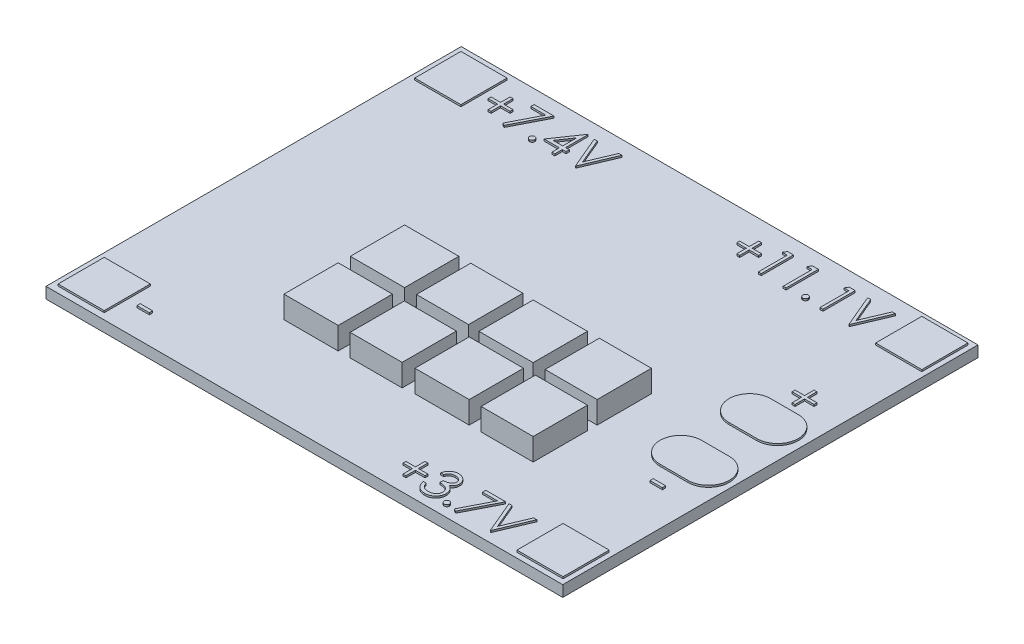
from build123d import *

# Parameters (mm, degrees)
SKETCH1_W            = 56
SKETCH1_H            = 45
BOSS_EXTRUDE1_DEPTH  = 1.2
SKETCH2_W            = 5
SKETCH2_H            = 5
BOSS_EXTRUDE2_DEPTH  = 0.2
BOSS_EXTRUDE3_DEPTH  = 0.2
SKETCH4_W            = 5.880082878
SKETCH4_H            = 5.880082878
SKETCH4_H_2          = 5.880082877
SKETCH4_W_2          = 5.641055118
BOSS_EXTRUDE4_DEPTH  = 2.4
BOSS_EXTRUDE5_DEPTH  = 0.2
SKETCH6_W            = 1.346153846
SKETCH6_H            = 0.358974359
BOSS_EXTRUDE6_DEPTH  = 0.2
BOSS_EXTRUDE7_DEPTH  = 0.2
BOSS_EXTRUDE8_DEPTH  = 0.2
BOSS_EXTRUDE9_DEPTH  = 0.2
SKETCH10_W           = 1.346153846
SKETCH10_H           = 0.358974359
BOSS_EXTRUDE10_DEPTH = 0.2


with BuildPart() as part:
    # Sketch1 → Boss-Extrude1 (new body)
    with BuildSketch(Plane(origin=(0, 0, 0), x_dir=(1, 0, 0), z_dir=(0, 1, 0))):
        with Locations((-4.877024793, 1.28214876)):
            Rectangle(SKETCH1_W, SKETCH1_H)
    extrude(amount=BOSS_EXTRUDE1_DEPTH)

    # Sketch2 → Boss-Extrude2 (add)
    with BuildSketch(Plane(origin=(0, 1.2, 0), x_dir=(1, 0, 0), z_dir=(0, 1, 0))):
        with Locations((-29.743077104, 20.608694888)):
            Rectangle(SKETCH2_W, SKETCH2_H)
        with Locations((20.094600179, 20.719328601)):
            Rectangle(SKETCH2_W, SKETCH2_H)
        with Locations((20.094600179, -18.155031081)):
            Rectangle(SKETCH2_W, SKETCH2_H)
        with Locations((-29.743077104, -18.044397367)):
            Rectangle(SKETCH2_W, SKETCH2_H)
    extrude(amount=BOSS_EXTRUDE2_DEPTH)

    # Sketch3 → Boss-Extrude3 (add)
    with BuildSketch(Plane(origin=(0, 1.2, 0), x_dir=(1, 0, 0), z_dir=(0, 1, 0))):
        with BuildLine():
            Line((17.297407854, -4.845624673), (20.309157621, -4.845624673))
            ThreePointArc((20.309157621, -4.845624673), (22.556018558, -2.598763736), (20.309157621, -0.351902799))
            Line((20.309157621, -0.351902799), (17.297407854, -0.351902799))
            ThreePointArc((17.297407854, -0.351902799), (15.050546917, -2.598763736), (17.297407854, -4.845624673))
        make_face()
        with BuildLine():
            Line((17.117440651, 2.810367146), (20.129190418, 2.810367146))
            ThreePointArc((20.129190418, 2.810367146), (22.376051355, 5.057228083), (20.129190418, 7.30408902))
            Line((20.129190418, 7.30408902), (17.117440651, 7.30408902))
            ThreePointArc((17.117440651, 7.30408902), (14.870579714, 5.057228083), (17.117440651, 2.810367146))
        make_face()
    extrude(amount=BOSS_EXTRUDE3_DEPTH)

    # Sketch4 → Boss-Extrude4 (add)
    with BuildSketch(Plane(origin=(0, 1.2, 0), x_dir=(1, 0, 0), z_dir=(0, 1, 0))):
        with Locations((-13.912274093, -8.517989369)):
            Rectangle(SKETCH4_W, SKETCH4_H)
        with Locations((-13.864468541, -1.371059368)):
            Rectangle(SKETCH4_W, SKETCH4_H_2)
        with Locations((-6.813149643, -1.371059368)):
            Rectangle(SKETCH4_W_2, SKETCH4_H_2)
        with Locations((-6.860955195, -8.517989369)):
            Rectangle(SKETCH4_W_2, SKETCH4_H)
        with Locations((0.142558151, -1.442767695)):
            Rectangle(SKETCH4_W, SKETCH4_H)
        with Locations((7.193877049, -1.442767695)):
            Rectangle(SKETCH4_W_2, SKETCH4_H)
        with Locations((0.142558151, -8.374572714)):
            Rectangle(SKETCH4_W, SKETCH4_H_2)
        with Locations((7.193877049, -8.374572714)):
            Rectangle(SKETCH4_W_2, SKETCH4_H_2)
    extrude(amount=BOSS_EXTRUDE4_DEPTH)

    # Sketch5 → Boss-Extrude5 (add)
    with BuildSketch(Plane(origin=(0, 1.2, 0), x_dir=(1, 0, 0), z_dir=(0, 1, 0))):
        Polygon((1.695992547, 20.415394793), (1.695992547, 21.447446075), (2.010095111, 21.447446075), (2.010095111, 20.415394793), (3.042146393, 20.415394793), (3.042146393, 20.101292229), (2.010095111, 20.101292229), (2.010095111, 19.069240947), (1.695992547, 19.069240947), (1.695992547, 20.101292229), (0.663941265, 20.101292229), (0.663941265, 20.415394793), align=None)
        Polygon((4.234754566, 22.030779409), (4.881889983, 22.030779409), (4.881889983, 18.530779409), (4.567787419, 18.530779409), (4.567787419, 21.67180505), (4.02932588, 21.67180505), align=None)
        Polygon((6.927062258, 22.030779409), (7.574197675, 22.030779409), (7.574197675, 18.530779409), (7.260095111, 18.530779409), (7.260095111, 21.67180505), (6.721633572, 21.67180505), align=None)
        with BuildLine():
            add(Edge.make_bspline(
                [(9.436377162, 19.069240947), (9.455867374, 19.06808278), (9.494075657, 19.06581233), (9.549314785, 19.050235656), (9.599309445, 19.022576996), (9.64384169, 18.985714217), (9.680548166, 18.941018554), (9.709192518, 18.891422646), (9.724633503, 18.835721053), (9.726887415, 18.797291378), (9.728043829, 18.77757428)],
                knots=[0, 0, 0, 0, 5.8463e-05, 0.000114609, 0.000170453, 0.000228714, 0.000286975, 0.000343156, 0.000399303, 0.000458464, 0.000458464, 0.000458464, 0.000458464], degree=3))
            add(Edge.make_bspline(
                [(9.728043829, 18.77757428), (9.726848228, 18.758330951), (9.724490521, 18.720383387), (9.709227913, 18.665101924), (9.680329863, 18.61547502), (9.64409487, 18.570172882), (9.599298436, 18.533232011), (9.54919659, 18.505808666), (9.494205332, 18.489116687), (9.455889008, 18.486990389), (9.436377162, 18.485907614)],
                knots=[0, 0, 0, 0, 5.7765e-05, 0.000113912, 0.000170093, 0.000228896, 0.000287156, 0.000343, 0.000399343, 0.000457806, 0.000457806, 0.000457806, 0.000457806], degree=3))
            add(Edge.make_bspline(
                [(9.436377162, 18.485907614), (9.416851257, 18.486951211), (9.378731574, 18.488988586), (9.32394558, 18.506151392), (9.273538611, 18.532974853), (9.228750899, 18.570241762), (9.192212428, 18.615241905), (9.164587045, 18.665443702), (9.147996896, 18.720225139), (9.145815023, 18.758299782), (9.144710496, 18.77757428)],
                knots=[0, 0, 0, 0, 5.8463e-05, 0.000114135, 0.000170596, 0.000228856, 0.000287659, 0.000343502, 0.000399846, 0.000457611, 0.000457611, 0.000457611, 0.000457611], degree=3))
            add(Edge.make_bspline(
                [(9.144710496, 18.77757428), (9.145772595, 18.79732366), (9.147846213, 18.8358819), (9.164621873, 18.891081008), (9.191998085, 18.941249447), (9.22900348, 18.985646027), (9.273527776, 19.02283333), (9.323823981, 19.049898123), (9.378863522, 19.065938535), (9.41687346, 19.068121052), (9.436377162, 19.069240947)],
                knots=[0, 0, 0, 0, 5.9161e-05, 0.000115504, 0.000171348, 0.000229609, 0.000287869, 0.00034433, 0.000399803, 0.000458266, 0.000458266, 0.000458266, 0.000458266], degree=3))
        make_face()
        Polygon((10.920652002, 22.030779409), (11.567787419, 22.030779409), (11.567787419, 18.530779409), (11.253684855, 18.530779409), (11.253684855, 21.67180505), (10.715223316, 21.67180505), align=None)
        Polygon((12.913941265, 22.030779409), (13.250479726, 22.030779409), (14.417146393, 19.272566268), (15.58381306, 22.030779409), (15.920351521, 22.030779409), (14.43958229, 18.530779409), (14.394710496, 18.530779409), align=None)
    extrude(amount=BOSS_EXTRUDE5_DEPTH)

    # Sketch6 → Boss-Extrude6 (add)
    with BuildSketch(Plane(origin=(0, 1.2, 0), x_dir=(1, 0, 0), z_dir=(0, 1, 0))):
        with Locations((-25.271094731, -18.119306896)):
            Rectangle(SKETCH6_W, SKETCH6_H)
    extrude(amount=BOSS_EXTRUDE6_DEPTH)

    # Sketch7 → Boss-Extrude7 (add)
    with BuildSketch(Plane(origin=(0, 1.2, 0), x_dir=(1, 0, 0), z_dir=(0, 1, 0))):
        Polygon((4.288270537, -18.345734188), (4.288270537, -17.313682906), (4.602373101, -17.313682906), (4.602373101, -18.345734188), (5.634424383, -18.345734188), (5.634424383, -18.659836752), (4.602373101, -18.659836752), (4.602373101, -19.691888034), (4.288270537, -19.691888034), (4.288270537, -18.659836752), (3.256219255, -18.659836752), (3.256219255, -18.345734188), align=None)
        with BuildLine():
            Line((6.531860281, -17.53804188), (6.217757717, -17.53804188))
            add(Edge.make_bspline(
                [(6.217757717, -17.53804188), (6.226267267, -17.502809396), (6.242902743, -17.433932772), (6.277600316, -17.335525511), (6.315399572, -17.242401989), (6.360788676, -17.156305916), (6.41029743, -17.075507013), (6.467020152, -17.001837888), (6.528339875, -16.933424923), (6.596164824, -16.872711685), (6.667293485, -16.817733956), (6.742728105, -16.770858899), (6.820950999, -16.730534746), (6.902504132, -16.697314514), (6.987630304, -16.672288991), (7.075559927, -16.654132185), (7.166523427, -16.642341071), (7.228271018, -16.641190308), (7.259624704, -16.640605983)],
                knots=[0, 0, 0, 0, 0.000108665, 0.000212431, 0.000312691, 0.000409905, 0.000504067, 0.000596618, 0.000688443, 0.000779278, 0.000869306, 0.00095782, 0.001045306, 0.001133058, 0.001221569, 0.001311085, 0.001402223, 0.001496238, 0.001496238, 0.001496238, 0.001496238], degree=3))
            add(Edge.make_bspline(
                [(7.259624704, -16.640605983), (7.305307446, -16.641985213), (7.395676457, -16.644713588), (7.528439504, -16.669628025), (7.656466323, -16.709053157), (7.778355571, -16.763526884), (7.891574003, -16.830714197), (7.99231019, -16.910678934), (8.079198701, -17.001878236), (8.152093079, -17.1026108), (8.209168078, -17.210266309), (8.251254451, -17.321066467), (8.276876132, -17.434748438), (8.280196689, -17.511505717), (8.281860281, -17.54996095)],
                knots=[0, 0, 0, 0, 0.000136936, 0.000270885, 0.000403723, 0.000538055, 0.000670441, 0.000797677, 0.000922646, 0.001047185, 0.00116951, 0.001287103, 0.001401935, 0.001517226, 0.001517226, 0.001517226, 0.001517226], degree=3))
            add(Edge.make_bspline(
                [(8.281860281, -17.54996095), (8.28069669, -17.586967745), (8.278419723, -17.6593843), (8.259086017, -17.765105797), (8.226549754, -17.864747397), (8.181479992, -17.958728559), (8.123138441, -18.046453399), (8.052465745, -18.12811929), (7.968963083, -18.204088448), (7.905684145, -18.247607921), (7.873106274, -18.270013034)],
                knots=[0, 0, 0, 0, 0.000110957, 0.000217125, 0.000321111, 0.000424595, 0.000528824, 0.000636204, 0.000747885, 0.000866393, 0.000866393, 0.000866393, 0.000866393], degree=3))
            add(Edge.make_bspline(
                [(7.873106274, -18.270013034), (7.910338029, -18.287991205), (7.984104903, -18.323611163), (8.084655433, -18.39346692), (8.175933308, -18.474123268), (8.226837027, -18.537065921), (8.252413165, -18.568690918)],
                knots=[0, 0, 0, 0, 0.000123863, 0.000245408, 0.000366052, 0.000487879, 0.000487879, 0.000487879, 0.000487879], degree=3))
            add(Edge.make_bspline(
                [(8.252413165, -18.568690918), (8.269254508, -18.59174867), (8.302661404, -18.637486587), (8.343896938, -18.711023013), (8.381306052, -18.785374502), (8.410456271, -18.862533908), (8.433030138, -18.941606922), (8.44916617, -19.022729318), (8.459190311, -19.10596734), (8.460625863, -19.16227982), (8.46134746, -19.19058595)],
                knots=[0, 0, 0, 0, 8.5583e-05, 0.000169764, 0.000252544, 0.000335098, 0.000416766, 0.000498992, 0.000583001, 0.000667909, 0.000667909, 0.000667909, 0.000667909], degree=3))
            add(Edge.make_bspline(
                [(8.46134746, -19.19058595), (8.459552947, -19.239595672), (8.455972365, -19.337384474), (8.42396829, -19.481859195), (8.37435505, -19.623084697), (8.303898114, -19.758159537), (8.218030605, -19.884539918), (8.115873281, -19.997616227), (7.998586872, -20.094814831), (7.867781224, -20.176025059), (7.726064095, -20.240942981), (7.574488503, -20.286000424), (7.415238449, -20.315346424), (7.306031152, -20.318493293), (7.250510121, -20.320093162)],
                knots=[0, 0, 0, 0, 0.000146863, 0.000293035, 0.000441833, 0.000594857, 0.000748684, 0.000899086, 0.001050437, 0.001204129, 0.001359752, 0.001516561, 0.001677477, 0.001843893, 0.001843893, 0.001843893, 0.001843893], degree=3))
            add(Edge.make_bspline(
                [(7.250510121, -20.320093162), (7.21309082, -20.319224949), (7.139462115, -20.317516595), (7.031218617, -20.305837993), (6.927896917, -20.284507988), (6.82935732, -20.255804683), (6.735512283, -20.219412941), (6.646648178, -20.174094243), (6.562218285, -20.120782741), (6.483019333, -20.058849153), (6.409060766, -19.989567813), (6.342308041, -19.911708803), (6.281648249, -19.826711399), (6.22870561, -19.733588343), (6.181068657, -19.633543086), (6.141887701, -19.525294587), (6.107402132, -19.409810565), (6.091368668, -19.329332825), (6.083142332, -19.28804188)],
                knots=[0, 0, 0, 0, 0.000112258, 0.000220887, 0.000326076, 0.000428356, 0.000528479, 0.000627563, 0.000727152, 0.000827569, 0.00092875, 0.001030654, 0.001134734, 0.001241526, 0.001351611, 0.001466743, 0.00158655, 0.001712791, 0.001712791, 0.001712791, 0.001712791], degree=3))
            Line((6.083142332, -19.28804188), (6.397244896, -19.28804188))
            add(Edge.make_bspline(
                [(6.397244896, -19.28804188), (6.405428188, -19.314990893), (6.4213454, -19.367409065), (6.448439698, -19.442849371), (6.47930797, -19.512007424), (6.512422529, -19.575390546), (6.547200975, -19.633622948), (6.5861159, -19.685164817), (6.626285045, -19.732280019), (6.656564399, -19.758824631), (6.671383518, -19.771815918)],
                knots=[0, 0, 0, 0, 8.4487e-05, 0.000164335, 0.000240293, 0.00031148, 0.000378817, 0.000443461, 0.000505064, 0.000564113, 0.000564113, 0.000564113, 0.000564113], degree=3))
            add(Edge.make_bspline(
                [(6.671383518, -19.771815918), (6.690980095, -19.786924252), (6.730112757, -19.817094284), (6.793880989, -19.855595913), (6.860945875, -19.888956938), (6.932760549, -19.914440634), (7.007775319, -19.936018294), (7.087202685, -19.950138814), (7.170341902, -19.959826985), (7.227109665, -19.960681916), (7.256119095, -19.961118803)],
                knots=[0, 0, 0, 0, 7.418e-05, 0.000148131, 0.000223072, 0.000298488, 0.0003764, 0.000456984, 0.000540217, 0.000627201, 0.000627201, 0.000627201, 0.000627201], degree=3))
            add(Edge.make_bspline(
                [(7.256119095, -19.961118803), (7.288872598, -19.960502898), (7.352919245, -19.959298548), (7.446374104, -19.948222841), (7.535281551, -19.932092428), (7.618654477, -19.907179445), (7.697584985, -19.876398594), (7.770966634, -19.837750188), (7.83976274, -19.792405467), (7.903092146, -19.740866308), (7.960037653, -19.684444813), (8.010177167, -19.625431742), (8.052801828, -19.564075912), (8.087185406, -19.500037791), (8.114335957, -19.433582562), (8.132819157, -19.364523733), (8.145670672, -19.293426467), (8.146717284, -19.245097498), (8.147244896, -19.220734188)],
                knots=[0, 0, 0, 0, 9.822e-05, 0.00019206, 0.00028199, 0.000368957, 0.000452673, 0.000535779, 0.000617257, 0.000699492, 0.000780303, 0.000857417, 0.000931514, 0.001003978, 0.001075065, 0.001146335, 0.001218144, 0.001291145, 0.001291145, 0.001291145, 0.001291145], degree=3))
            add(Edge.make_bspline(
                [(8.147244896, -19.220734188), (8.145714595, -19.188122849), (8.142661606, -19.123062441), (8.119353027, -19.027344866), (8.081014163, -18.935121454), (8.027341651, -18.847965664), (7.962005923, -18.767189762), (7.885641016, -18.69511828), (7.797612787, -18.635648189), (7.716592918, -18.594559532), (7.644827762, -18.566522457), (7.583412377, -18.547847493), (7.514655774, -18.532033837), (7.439389425, -18.517321565), (7.357046209, -18.504800217), (7.267715771, -18.494358402), (7.171380009, -18.486003361), (7.104688843, -18.482272265), (7.070321819, -18.480349572)],
                knots=[0, 0, 0, 0, 9.7761e-05, 0.000195035, 0.000293731, 0.000396299, 0.00050098, 0.000604654, 0.000710058, 0.000818548, 0.000876487, 0.000941025, 0.001010919, 0.001088059, 0.001171055, 0.001260716, 0.001357836, 0.001461094, 0.001461094, 0.001461094, 0.001461094], degree=3))
            Line((7.070321819, -18.480349572), (7.070321819, -18.121375213))
            add(Edge.make_bspline(
                [(7.070321819, -18.121375213), (7.113622985, -18.12064041), (7.198439332, -18.11920111), (7.322333636, -18.101793099), (7.440806948, -18.077712471), (7.55123369, -18.040827279), (7.651882404, -17.997986982), (7.739202006, -17.948134773), (7.811969153, -17.892720023), (7.869830225, -17.830887414), (7.913359453, -17.764572366), (7.945186251, -17.695455709), (7.963986577, -17.622931648), (7.966496244, -17.57343698), (7.967757717, -17.548558707)],
                knots=[0, 0, 0, 0, 0.0001298, 0.000254247, 0.000374709, 0.000491998, 0.000602842, 0.000702416, 0.000792872, 0.000876214, 0.000955164, 0.001029842, 0.001103644, 0.00117823, 0.00117823, 0.00117823, 0.00117823], degree=3))
            add(Edge.make_bspline(
                [(7.967757717, -17.548558707), (7.967343306, -17.530280962), (7.966518855, -17.493918255), (7.956121577, -17.440793186), (7.940497536, -17.38929224), (7.919017807, -17.33963443), (7.890267608, -17.292164156), (7.855861622, -17.246476707), (7.814893521, -17.202832928), (7.767948074, -17.162152608), (7.717536269, -17.123383371), (7.662286494, -17.090469734), (7.60386462, -17.062324672), (7.542205965, -17.03911517), (7.477110434, -17.021655882), (7.408883877, -17.00912004), (7.337396193, -17.001282386), (7.288624461, -17.00015397), (7.263831435, -16.999580342)],
                knots=[0, 0, 0, 0, 5.4759e-05, 0.000108941, 0.000161726, 0.000216044, 0.000270754, 0.000327825, 0.00038735, 0.000449943, 0.000514025, 0.000577874, 0.000642472, 0.000708366, 0.000775209, 0.000844379, 0.000916308, 0.00099068, 0.00099068, 0.00099068, 0.00099068], degree=3))
            add(Edge.make_bspline(
                [(7.263831435, -16.999580342), (7.223979767, -17.000971704), (7.14614019, -17.003689357), (7.033925273, -17.027492371), (6.929605939, -17.065470454), (6.849867273, -17.110803473), (6.790984699, -17.155553907), (6.74890776, -17.194636294), (6.70758725, -17.238069117), (6.669741573, -17.288527493), (6.631467597, -17.342594283), (6.596623035, -17.403017964), (6.562763343, -17.468222359), (6.542360793, -17.514317993), (6.531860281, -17.53804188)],
                knots=[0, 0, 0, 0, 0.00011944, 0.000233294, 0.000342435, 0.0004514, 0.000506931, 0.000563998, 0.000623523, 0.000686492, 0.000753006, 0.000822147, 0.000895524, 0.000973336, 0.000973336, 0.000973336, 0.000973336], degree=3))
        make_face()
        with BuildLine():
            add(Edge.make_bspline(
                [(9.33634746, -19.691888034), (9.355837673, -19.693046201), (9.394045955, -19.695316651), (9.449285083, -19.710893325), (9.499279743, -19.738551985), (9.543811988, -19.775414763), (9.580518464, -19.820110427), (9.609162816, -19.869706335), (9.624603802, -19.925407928), (9.626857713, -19.963837603), (9.628014127, -19.9835547)],
                knots=[0, 0, 0, 0, 5.8463e-05, 0.000114609, 0.000170453, 0.000228714, 0.000286975, 0.000343156, 0.000399303, 0.000458464, 0.000458464, 0.000458464, 0.000458464], degree=3))
            add(Edge.make_bspline(
                [(9.628014127, -19.9835547), (9.626818526, -20.00279803), (9.624460819, -20.040745594), (9.609198211, -20.096027057), (9.580300161, -20.145653961), (9.544065168, -20.190956099), (9.499268734, -20.22789697), (9.449166888, -20.255320315), (9.39417563, -20.272012294), (9.355859306, -20.274138592), (9.33634746, -20.275221367)],
                knots=[0, 0, 0, 0, 5.7765e-05, 0.000113912, 0.000170093, 0.000228896, 0.000287156, 0.000343, 0.000399343, 0.000457806, 0.000457806, 0.000457806, 0.000457806], degree=3))
            add(Edge.make_bspline(
                [(9.33634746, -20.275221367), (9.316821555, -20.27417777), (9.278701872, -20.272140395), (9.223915878, -20.254977589), (9.173508909, -20.228154128), (9.128721198, -20.190887219), (9.092182726, -20.145887076), (9.064557343, -20.095685279), (9.047967194, -20.040903842), (9.045785321, -20.002829199), (9.044680794, -19.9835547)],
                knots=[0, 0, 0, 0, 5.8463e-05, 0.000114135, 0.000170596, 0.000228856, 0.000287659, 0.000343502, 0.000399846, 0.000457611, 0.000457611, 0.000457611, 0.000457611], degree=3))
            add(Edge.make_bspline(
                [(9.044680794, -19.9835547), (9.045742893, -19.963805321), (9.047816511, -19.925247081), (9.064592172, -19.870047973), (9.091968384, -19.819879534), (9.128973779, -19.775482954), (9.173498074, -19.738295651), (9.22379428, -19.711230858), (9.27883382, -19.695190446), (9.316843758, -19.693007929), (9.33634746, -19.691888034)],
                knots=[0, 0, 0, 0, 5.9161e-05, 0.000115504, 0.000171348, 0.000229609, 0.000287869, 0.00034433, 0.000399803, 0.000458266, 0.000458266, 0.000458266, 0.000458266], degree=3))
        make_face()
        Polygon((10.30109105, -16.730349572), (12.454937204, -16.730349572), (10.615193614, -20.320093162), (10.34385948, -20.17075422), (11.923486883, -17.089323931), (10.30109105, -17.089323931), align=None)
        Polygon((12.813911563, -16.730349572), (13.150450024, -16.730349572), (14.317116691, -19.488562713), (15.483783358, -16.730349572), (15.820321819, -16.730349572), (14.339552589, -20.230349572), (14.294680794, -20.230349572), align=None)
    extrude(amount=BOSS_EXTRUDE7_DEPTH)

    # Sketch8 → Boss-Extrude8 (add)
    with BuildSketch(Plane(origin=(0, 1.2, 0), x_dir=(1, 0, 0), z_dir=(0, 1, 0))):
        Polygon((-25.303366058, 20.472373915), (-25.303366058, 21.504425197), (-24.989263494, 21.504425197), (-24.989263494, 20.472373915), (-23.957212212, 20.472373915), (-23.957212212, 20.158271351), (-24.989263494, 20.158271351), (-24.989263494, 19.126220069), (-25.303366058, 19.126220069), (-25.303366058, 20.158271351), (-26.33541734, 20.158271351), (-26.33541734, 20.472373915), align=None)
        Polygon((-23.284135289, 22.08775853), (-21.130289135, 22.08775853), (-22.970032725, 18.49801494), (-23.241366859, 18.647353883), (-21.661739455, 21.728784171), (-23.284135289, 21.728784171), align=None)
        with BuildLine():
            add(Edge.make_bspline(
                [(-20.255289135, 19.126220069), (-20.235798923, 19.125061902), (-20.19759064, 19.122791452), (-20.142351512, 19.107214778), (-20.092356852, 19.079556117), (-20.047824608, 19.042693339), (-20.011118131, 18.997997676), (-19.982473779, 18.948401767), (-19.967032794, 18.892700174), (-19.964778882, 18.8542705), (-19.963622468, 18.834553402)],
                knots=[0, 0, 0, 0, 5.8463e-05, 0.000114609, 0.000170453, 0.000228714, 0.000286975, 0.000343156, 0.000399303, 0.000458464, 0.000458464, 0.000458464, 0.000458464], degree=3))
            add(Edge.make_bspline(
                [(-19.963622468, 18.834553402), (-19.964818069, 18.815310072), (-19.967175776, 18.777362508), (-19.982438384, 18.722081046), (-20.011336435, 18.672454141), (-20.047571427, 18.627152003), (-20.092367861, 18.590211133), (-20.142469707, 18.562787788), (-20.197460966, 18.546095808), (-20.235777289, 18.543969511), (-20.255289135, 18.542886735)],
                knots=[0, 0, 0, 0, 5.7765e-05, 0.000113912, 0.000170093, 0.000228896, 0.000287156, 0.000343, 0.000399343, 0.000457806, 0.000457806, 0.000457806, 0.000457806], degree=3))
            add(Edge.make_bspline(
                [(-20.255289135, 18.542886735), (-20.274815041, 18.543930332), (-20.312934723, 18.545967707), (-20.367720717, 18.563130514), (-20.418127686, 18.589953974), (-20.462915398, 18.627220883), (-20.499453869, 18.672221027), (-20.527079252, 18.722422823), (-20.543669401, 18.777204261), (-20.545851274, 18.815278904), (-20.546955802, 18.834553402)],
                knots=[0, 0, 0, 0, 5.8463e-05, 0.000114135, 0.000170596, 0.000228856, 0.000287659, 0.000343502, 0.000399846, 0.000457611, 0.000457611, 0.000457611, 0.000457611], degree=3))
            add(Edge.make_bspline(
                [(-20.546955802, 18.834553402), (-20.545893702, 18.854302782), (-20.543820084, 18.892861022), (-20.527044424, 18.948060129), (-20.499668212, 18.998228568), (-20.462662817, 19.042625148), (-20.418138521, 19.079812451), (-20.367842316, 19.106877244), (-20.312802775, 19.122917656), (-20.274792837, 19.125100173), (-20.255289135, 19.126220069)],
                knots=[0, 0, 0, 0, 5.9161e-05, 0.000115504, 0.000171348, 0.000229609, 0.000287869, 0.00034433, 0.000399803, 0.000458266, 0.000458266, 0.000458266, 0.000458266], degree=3))
        make_face()
        Polygon((-17.604347629, 22.17750212), (-17.540545545, 22.17750212), (-17.540545545, 19.754425197), (-17.136699391, 19.754425197), (-17.136699391, 19.395450838), (-17.540545545, 19.395450838), (-17.540545545, 18.58775853), (-17.854648109, 18.58775853), (-17.854648109, 19.395450838), (-19.51490452, 19.395450838), align=None)
        Polygon((-17.854648109, 19.754425197), (-17.854648109, 21.274457248), (-18.89791734, 19.754425197), align=None, mode=Mode.SUBTRACT)
        Polygon((-16.777725032, 22.08775853), (-16.441186571, 22.08775853), (-15.274519904, 19.329545389), (-14.107853238, 22.08775853), (-13.771314776, 22.08775853), (-15.252084007, 18.58775853), (-15.296955802, 18.58775853), align=None)
    extrude(amount=BOSS_EXTRUDE8_DEPTH)

    # Sketch9 → Boss-Extrude9 (add)
    with BuildSketch(Plane(origin=(0, 1.2, 0), x_dir=(1, 0, 0), z_dir=(0, 1, 0))):
        Polygon((18.677741644, 9.429291437), (18.677741644, 10.461342719), (18.991844208, 10.461342719), (18.991844208, 9.429291437), (20.02389549, 9.429291437), (20.02389549, 9.115188873), (18.991844208, 9.115188873), (18.991844208, 8.083137591), (18.677741644, 8.083137591), (18.677741644, 9.115188873), (17.645690362, 9.115188873), (17.645690362, 9.429291437), align=None)
    extrude(amount=BOSS_EXTRUDE9_DEPTH)

    # Sketch10 → Boss-Extrude10 (add)
    with BuildSketch(Plane(origin=(0, 1.2, 0), x_dir=(1, 0, 0), z_dir=(0, 1, 0))):
        with Locations((18.94904073, -6.741585557)):
            Rectangle(SKETCH10_W, SKETCH10_H)
    extrude(amount=BOSS_EXTRUDE10_DEPTH)


solid = part.part
